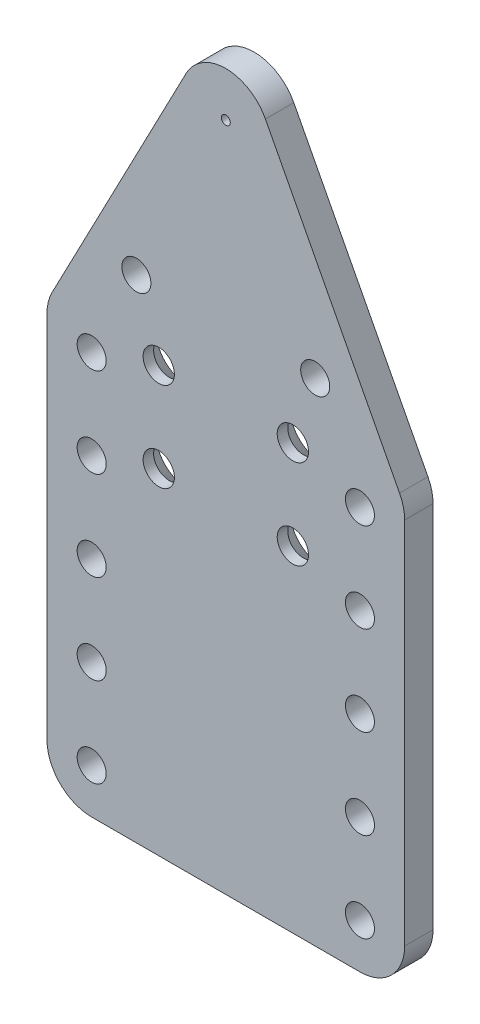
from build123d import *

# Parameters (mm, degrees)
SKETCH1_R             = 3.5
BOSS_EXTRUDE1_DEPTH   = 6.35
SKETCH2_R             = 3.25
CUT_EXTRUDE1_DEPTH    = 7.35
LPATTERN1_COUNT       = 5
LPATTERN1_PITCH       = 20
FILLET1_R             = 10
SKETCH3_R             = 3.25
SKETCH3_R_2           = 1
CUT_EXTRUDE2_DEPTH    = 7.35
CHAMFER1_SIZE         = 4
CHAMFER1_SIZE2        = 3.477146951
CHAMFER1_PART_2_SIZE  = 4
CHAMFER1_PART_2_SIZE2 = 3.477146951
CHAMFER1_PART_3_SIZE  = 4
CHAMFER1_PART_3_SIZE2 = 3.477146951
CHAMFER1_PART_4_SIZE  = 4
CHAMFER1_PART_4_SIZE2 = 3.477146951


with BuildPart() as part:
    # Sketch1 → Boss-Extrude1 (new body)
    with BuildSketch(Plane.XY):
        with BuildLine():
            Line((-40, 47.5), (-8.864317001, 107.128594183))
            ThreePointArc((-8.864317001, 107.128594183), (0, 112.5), (8.864317001, 107.128594183))
            Line((8.864317001, 107.128594183), (40, 47.5))
            Line((40, 47.5), (40, -47.5))
            Line((40, -47.5), (-40, -47.5))
            Line((-40, -47.5), (-40, 47.5))
        make_face()
        with Locations((-15, 47.5)):
            Circle(SKETCH1_R, mode=Mode.SUBTRACT)
        with Locations((15, 47.5)):
            Circle(SKETCH1_R, mode=Mode.SUBTRACT)
        with Locations((-15, 27.5)):
            Circle(SKETCH1_R, mode=Mode.SUBTRACT)
        with Locations((15, 27.5)):
            Circle(SKETCH1_R, mode=Mode.SUBTRACT)
    extrude(amount=BOSS_EXTRUDE1_DEPTH)

    # Sketch2 → Cut-Extrude1 (cut, through all)
    with BuildSketch(Plane.XY.offset(6.35)):
        with Locations((30, -37.5)):
            Circle(SKETCH2_R)
        with Locations((-30, -37.5)):
            Circle(SKETCH2_R)
    cut_extrude1 = extrude(amount=-CUT_EXTRUDE1_DEPTH, mode=Mode.SUBTRACT)

    # LPattern1: Cut-Extrude1 ×5
    with Locations(*[(0, i * LPATTERN1_PITCH, 0) for i in range(1, LPATTERN1_COUNT)]):
        add(cut_extrude1, mode=Mode.SUBTRACT)

    # Fillet1
    fillet1_edges = [part.edges().sort_by_distance(p)[0] for p in [
        (40, 47.5, 3.175),
        (40, -47.5, 3.175),
        (-40, -47.5, 3.175),
        (-40, 47.5, 3.175),
    ]]
    fillet(fillet1_edges, radius=FILLET1_R)

    # Sketch3 → Cut-Extrude2 (cut, through all)
    with BuildSketch(Plane.XY.offset(6.35)):
        with Locations((-20, 62.5)):
            Circle(SKETCH3_R)
        with Locations((20, 62.5)):
            Circle(SKETCH3_R)
        with Locations((0, 102.5)):
            Circle(SKETCH3_R_2)
    extrude(amount=-CUT_EXTRUDE2_DEPTH, mode=Mode.SUBTRACT)

    # Chamfer1
    chamfer1_edges = [part.edges().sort_by_distance(p)[0] for p in [
        (-18.5, 47.5, 0),
    ]]
    chamfer1_side = [part.faces().sort_by_distance(p)[0] for p in [
        (-18.5, 47.5, 3.175),
    ]]
    chamfer(chamfer1_edges, length=CHAMFER1_SIZE, length2=CHAMFER1_SIZE2, reference=chamfer1_side[0])

    # Chamfer1 part 2
    chamfer1_part_2_edges = [part.edges().sort_by_distance(p)[0] for p in [
        (11.5, 47.5, 0),
    ]]
    chamfer1_part_2_side = [part.faces().sort_by_distance(p)[0] for p in [
        (11.5, 47.5, 3.175),
    ]]
    chamfer(chamfer1_part_2_edges, length=CHAMFER1_PART_2_SIZE, length2=CHAMFER1_PART_2_SIZE2, reference=chamfer1_part_2_side[0])

    # Chamfer1 part 3
    chamfer1_part_3_edges = [part.edges().sort_by_distance(p)[0] for p in [
        (-18.5, 27.5, 0),
    ]]
    chamfer1_part_3_side = [part.faces().sort_by_distance(p)[0] for p in [
        (-18.5, 27.5, 3.175),
    ]]
    chamfer(chamfer1_part_3_edges, length=CHAMFER1_PART_3_SIZE, length2=CHAMFER1_PART_3_SIZE2, reference=chamfer1_part_3_side[0])

    # Chamfer1 part 4
    chamfer1_part_4_edges = [part.edges().sort_by_distance(p)[0] for p in [
        (11.5, 27.5, 0),
    ]]
    chamfer1_part_4_side = [part.faces().sort_by_distance(p)[0] for p in [
        (11.5, 27.5, 3.175),
    ]]
    chamfer(chamfer1_part_4_edges, length=CHAMFER1_PART_4_SIZE, length2=CHAMFER1_PART_4_SIZE2, reference=chamfer1_part_4_side[0])


solid = part.part
